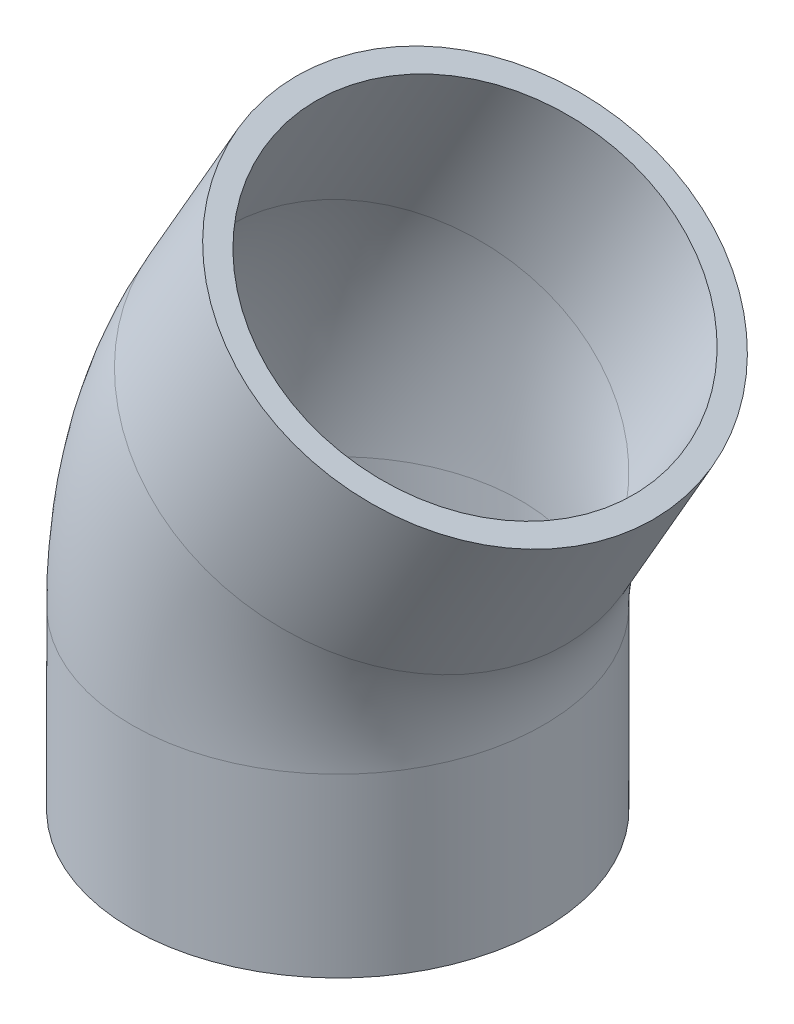
from build123d import *

# Parameters (mm, degrees)
SKETCH2_R   = 22.5
SKETCH2_R_2 = 20


with BuildPart() as part:
    # Sweep-Thin1: sweep along a curve in space
    with BuildLine() as sweep_thin1_path:
        Line((0, 0, 0), (0, 19.282032303, 0))
        ThreePointArc((0, 19.282032303, 0), (1.362966948, 29.634794107, 0), (5.358983849, 39.282032303, 0))
        Line((5.358983849, 39.282032303, 0), (15, 55.980762114, 0))
    # Sketch2 → Sweep-Thin1 (sweep)
    with BuildSketch(Plane(origin=(0, 0, 0), x_dir=(1, 0, 0), z_dir=(0, 1, 0))):
        Circle(SKETCH2_R)
        Circle(SKETCH2_R_2, mode=Mode.SUBTRACT)
    sweep(path=sweep_thin1_path.line)


solid = part.part
